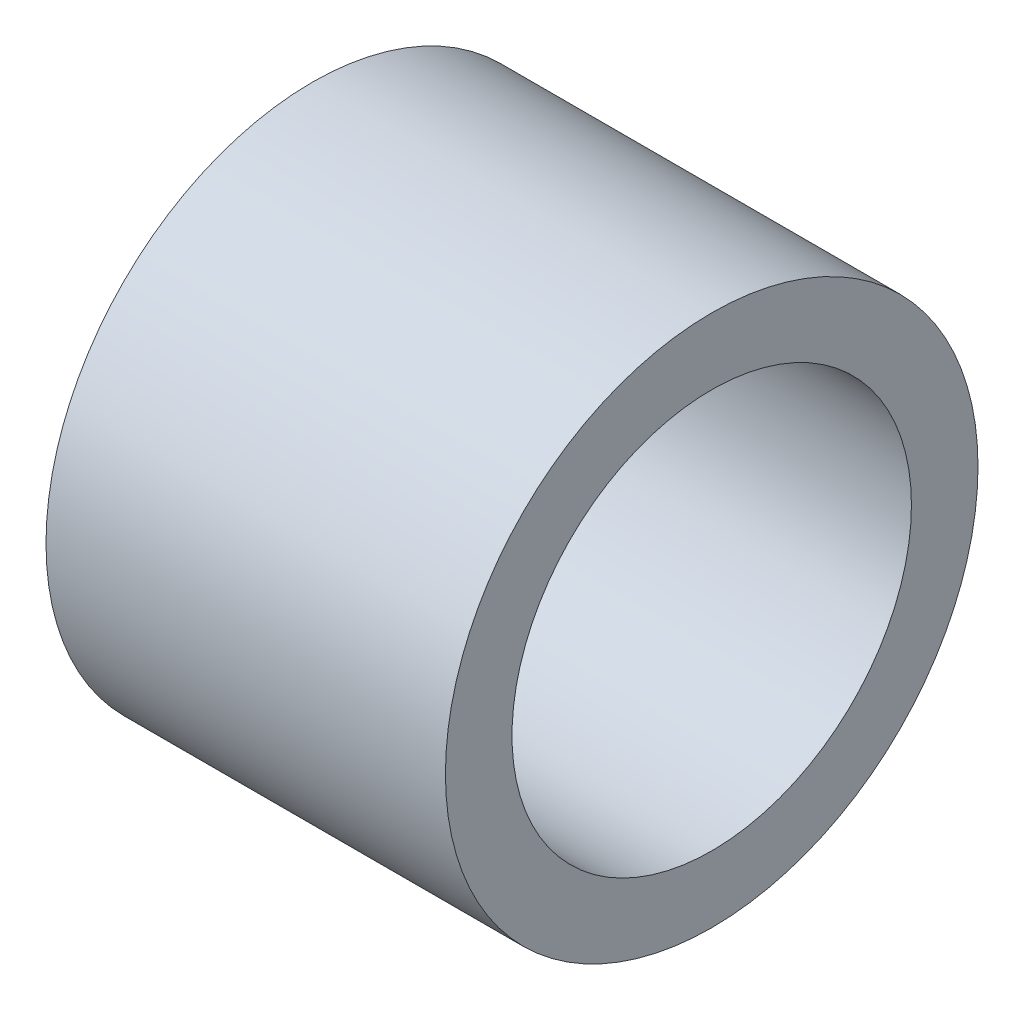
from build123d import *

# Parameters (mm, degrees)
ESQUISSE1_R        = 12.7
ESQUISSE1_R_2      = 9.525
BOSS_EXTRU_1_DEPTH = 9.525


with BuildPart() as part:
    # Esquisse1 → Boss.-Extru.1 (new body, symmetric)
    with BuildSketch(Plane(origin=(0, 0, 0), x_dir=(0, 0, -1), z_dir=(1, 0, 0))):
        Circle(ESQUISSE1_R)
        Circle(ESQUISSE1_R_2, mode=Mode.SUBTRACT)
    extrude(amount=BOSS_EXTRU_1_DEPTH, both=True)


solid = part.part
